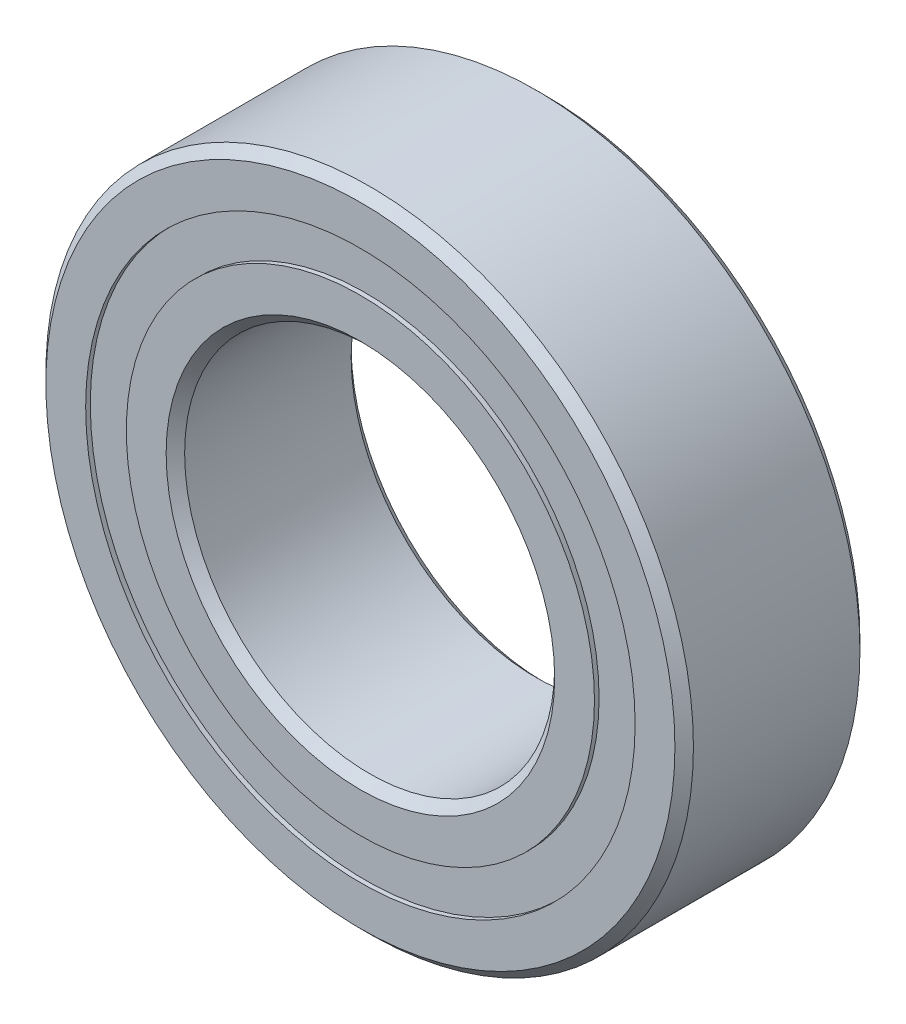
from build123d import *

# Parameters (mm, degrees)
CIRPATTERN1_COUNT = 12
SKETCH5_W         = 0.908366581
SKETCH5_H         = 0.87912088


with BuildPart() as part:
    # Sketch1 → Revolve1 (revolve)
    with BuildSketch(Plane(origin=(0, 0, 0), x_dir=(0, 0, -1), z_dir=(1, 0, 0))):
        with BuildLine():
            Line((1.8, 7), (-1.8, 7))
            Line((-1.8, 7), (-2, 6.8))
            Line((-2, 6.8), (-2, 5.93956044))
            Line((-2, 5.93956044), (-0.888888889, 5.93956044))
            ThreePointArc((-0.888888889, 5.93956044), (0, 6.491633419), (0.888888889, 5.93956044))
            Line((0.888888889, 5.93956044), (2, 5.93956044))
            Line((2, 5.93956044), (2, 6.8))
            Line((2, 6.8), (1.8, 7))
        make_face()
    revolve(axis=Axis((0, 0, 2), (0, 0, -1)))


with BuildPart() as body_2:
    # Sketch3 → Revolve3 (revolve)
    with BuildSketch(Plane(origin=(0, 0, 0), x_dir=(0, 0, -1), z_dir=(1, 0, 0))):
        with BuildLine():
            Line((-2, 5.06043956), (-0.888888889, 5.06043956))
            ThreePointArc((-0.888888889, 5.06043956), (0, 4.508366581), (0.888888889, 5.06043956))
            Line((0.888888889, 5.06043956), (2, 5.06043956))
            Line((2, 5.06043956), (2, 4.2))
            Line((2, 4.2), (1.8, 4))
            Line((1.8, 4), (-1.8, 4))
            Line((-1.8, 4), (-2, 4.2))
            Line((-2, 4.2), (-2, 5.06043956))
        make_face()
    revolve(axis=Axis((0, 0, 2), (0, 0, -1)))


with BuildPart() as body_3:
    # Sketch4 → Revolve4 (revolve)
    with BuildSketch(Plane(origin=(0, 0, 0), x_dir=(0, 0, -1), z_dir=(1, 0, 0))):
        with BuildLine():
            Line((-0.991633419, 5.5), (0.991633419, 5.5))
            ThreePointArc((0.991633419, 5.5), (0, 6.491633419), (-0.991633419, 5.5))
        make_face()
    revolve(axis=Axis((0, 5.5, 0.991633419), (0, 0, -1)))


with BuildPart() as cirpattern1_1:
    # CirPattern1: pattern copy
    add(body_3.part.rotate(Axis((0, 0, -2), (0, 0, 1)), 1 * 360 / CIRPATTERN1_COUNT))


with BuildPart() as cirpattern1_2:
    # CirPattern1: pattern copy
    add(body_3.part.rotate(Axis((0, 0, -2), (0, 0, 1)), 2 * 360 / CIRPATTERN1_COUNT))


with BuildPart() as cirpattern1_3:
    # CirPattern1: pattern copy
    add(body_3.part.rotate(Axis((0, 0, -2), (0, 0, 1)), 3 * 360 / CIRPATTERN1_COUNT))


with BuildPart() as cirpattern1_4:
    # CirPattern1: pattern copy
    add(body_3.part.rotate(Axis((0, 0, -2), (0, 0, 1)), 4 * 360 / CIRPATTERN1_COUNT))


with BuildPart() as cirpattern1_5:
    # CirPattern1: pattern copy
    add(body_3.part.rotate(Axis((0, 0, -2), (0, 0, 1)), 5 * 360 / CIRPATTERN1_COUNT))


with BuildPart() as cirpattern1_6:
    # CirPattern1: pattern copy
    add(body_3.part.rotate(Axis((0, 0, -2), (0, 0, 1)), 6 * 360 / CIRPATTERN1_COUNT))


with BuildPart() as cirpattern1_7:
    # CirPattern1: pattern copy
    add(body_3.part.rotate(Axis((0, 0, -2), (0, 0, 1)), 7 * 360 / CIRPATTERN1_COUNT))


with BuildPart() as cirpattern1_8:
    # CirPattern1: pattern copy
    add(body_3.part.rotate(Axis((0, 0, -2), (0, 0, 1)), 8 * 360 / CIRPATTERN1_COUNT))


with BuildPart() as cirpattern1_9:
    # CirPattern1: pattern copy
    add(body_3.part.rotate(Axis((0, 0, -2), (0, 0, 1)), 9 * 360 / CIRPATTERN1_COUNT))


with BuildPart() as cirpattern1_10:
    # CirPattern1: pattern copy
    add(body_3.part.rotate(Axis((0, 0, -2), (0, 0, 1)), 10 * 360 / CIRPATTERN1_COUNT))


with BuildPart() as cirpattern1_11:
    # CirPattern1: pattern copy
    add(body_3.part.rotate(Axis((0, 0, -2), (0, 0, 1)), 11 * 360 / CIRPATTERN1_COUNT))


with BuildPart() as body_15:
    # Sketch5 → Revolve5 (revolve)
    with BuildSketch(Plane(origin=(0, 0, 0), x_dir=(0, 0, -1), z_dir=(1, 0, 0))):
        with Locations((-1.44581671, 5.5)):
            Rectangle(SKETCH5_W, SKETCH5_H)
        with Locations((1.44581671, 5.5)):
            Rectangle(SKETCH5_W, SKETCH5_H)
    revolve(axis=Axis((0, 0, 2), (0, 0, -1)))


solid = Compound([part.part, body_2.part, body_3.part, cirpattern1_1.part, cirpattern1_2.part, cirpattern1_3.part, cirpattern1_4.part, cirpattern1_5.part, cirpattern1_6.part, cirpattern1_7.part, cirpattern1_8.part, cirpattern1_9.part, cirpattern1_10.part, cirpattern1_11.part, body_15.part])
